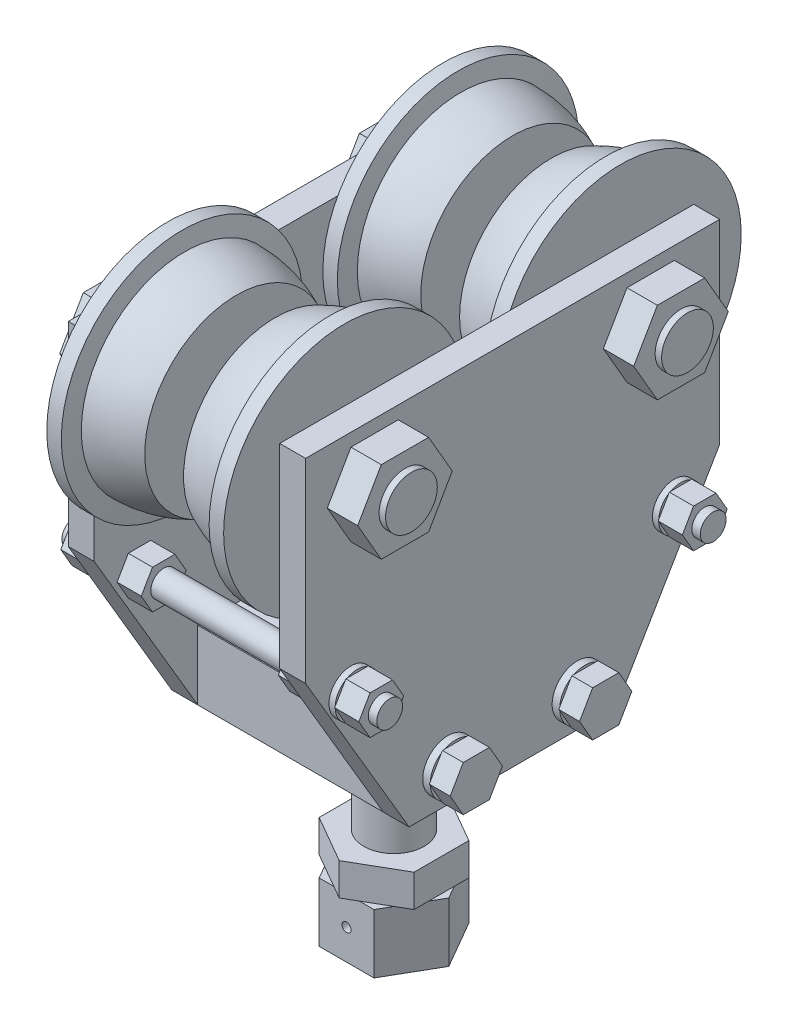
from build123d import *

# Parameters (mm, degrees)
YOKE_CROSS_SECTION_W           = 152.4
YOKE_CROSS_SECTION_H           = 50.8
YOKE_DEPTH                     = 68.2625
SIDEPLATE_DEPTH                = 19.05
WHEEL_PIN_NUT_DEPTH            = 22.352
WHEEL_PIN_PROJECTION_PROFILE_R = 19.05
WHEEL_PIN_PROJECTION_DEPTH     = 4.7625
LOCKNUTS_PROFILE_R             = 18.542
LOCKNUTS_DEPTH                 = 5.5626
SCREWS_DEPTH                   = 15.3416
PROFILE_R                      = 30.1625
KING_BOLT_HEAD_DEPTH           = 38.1
DIA_R                          = 22.225
KING_BOLT_DEPTH                = 83.052101
KING_BOLT_JAM_NUT_DEPTH        = 23.8125
KING_BOLT_NUT_DEPTH            = 43.6372
SKETCH5_R                      = 22.225
EXTENDED_KING_BOLT_DEPTH       = 9.525
CHAMFER1_SIZE                  = 2.38125
THREADED_START                 = -68.2625
SKETCH6_R                      = 9.525
THREADED_ROD_DEPTH             = 115.8875
THREADED_ROD_NUTS_INNER_DEPTH  = 17.8054
SKETCH8_R                      = 16.129
THREADED_ROD_LOCKWASHER_DEPTH  = 4.572
THREADED_ROD_NUT_OUTER_DEPTH   = 17.8054
MIRROR3_START                  = -68.2625
MIRROR3_COPY_1_SKETCH_R        = 9.525
MIRROR3_COPY_1_DEPTH           = 115.8875
MIRROR3_COPY_2_DEPTH           = 17.8054
MIRROR3_COPY_3_SKETCH_R        = 16.129
MIRROR3_COPY_3_DEPTH           = 4.572
MIRROR3_COPY_4_DEPTH           = 17.8054
SKETCH10_R                     = 3.3655
COTTER_PIN_HOLE_DEPTH          = 188.325


with BuildPart() as part:
    # YOKE CROSS SECTION → YOKE (new body)
    with BuildSketch(Plane(origin=(0, 0, 0), x_dir=(0, 0, -1), z_dir=(1, 0, 0))):
        with Locations((0, 25.4)):
            Rectangle(YOKE_CROSS_SECTION_W, YOKE_CROSS_SECTION_H)
    extrude(amount=YOKE_DEPTH)

    # SIDEPLATE PROFILE → SIDEPLATE (add)
    with BuildSketch(Plane(origin=(68.2625, 0, 0), x_dir=(0, 0, -1), z_dir=(1, 0, 0))):
        Polygon((-152.4, 273.05), (152.4, 273.05), (152.4, 129.54), (76.2, 0), (0, 0), (-76.2, 0), (-152.4, 129.54), align=None)
    extrude(amount=SIDEPLATE_DEPTH)

    # WHEEL PIN NUT PROFILE → WHEEL PIN NUT (add)
    with BuildSketch(Plane(origin=(87.3125, 0, 0), x_dir=(0, 0, -1), z_dir=(1, 0, 0))):
        Polygon((-66.771345011, 233.3625), (-84.185672506, 263.525), (-119.014327494, 263.525), (-136.428654989, 233.3625), (-119.014327494, 203.2), (-84.185672506, 203.2), align=None)
    wheel_pin_nut = extrude(amount=WHEEL_PIN_NUT_DEPTH)

    # WHEEL PIN PROJECTION PROFILE → WHEEL PIN PROJECTION (add)
    with BuildSketch(Plane(origin=(109.6645, 0, 0), x_dir=(0, 0, -1), z_dir=(1, 0, 0))):
        with Locations((-101.6, 233.3625)):
            Circle(WHEEL_PIN_PROJECTION_PROFILE_R)
    wheel_pin_projection = extrude(amount=WHEEL_PIN_PROJECTION_DEPTH)

    # LOCKNUTS PROFILE → LOCKNUTS (add)
    with BuildSketch(Plane(origin=(87.3125, 0, 0), x_dir=(0, 0, -1), z_dir=(1, 0, 0))):
        with Locations((-47.625, 25.4)):
            Circle(LOCKNUTS_PROFILE_R)
    locknuts = extrude(amount=LOCKNUTS_DEPTH)

    # SCREWS PROFILE → SCREWS (add)
    with BuildSketch(Plane(origin=(92.8751, 0, 0), x_dir=(0, 0, -1), z_dir=(1, 0, 0))):
        Polygon((-28.377585401, 25.4), (-38.0012927, 42.06875), (-57.2487073, 42.06875), (-66.872414599, 25.4), (-57.2487073, 8.73125), (-38.0012927, 8.73125), align=None)
    screws = extrude(amount=SCREWS_DEPTH)

    # PROFILE → KING BOLT HEAD (add)
    with BuildSketch(Plane(origin=(0, 50.8, 0), x_dir=(-1, 0, 0), z_dir=(0, 1, 0))):
        with Locations(Location((0, 0, 0), (0, 0, 90))):  # turned: the seam where the file's is
            Circle(PROFILE_R)
    extrude(amount=KING_BOLT_HEAD_DEPTH)

    # Mirror1: WHEEL PIN NUT, WHEEL PIN PROJECTION across plane
    add(wheel_pin_nut.mirror(Plane.XY))
    add(wheel_pin_projection.mirror(Plane.XY))

    # Mirror YOKE SCREWS: LOCKNUTS, SCREWS across plane
    add(locknuts.mirror(Plane.XY))
    add(screws.mirror(Plane.XY))

    # Mirror SIDE 1: part across plane


with BuildPart() as part_1:
    add(part.part)
    add(part.part.mirror(Plane(origin=(0, 0, 0), x_dir=(0, 0, 1), z_dir=(1, 0, 0))))

    # DIA. → KING BOLT (add)
    with BuildSketch(Plane.XZ):
        with Locations(Location((0, 0, 0), (0, 0, 90))):  # turned: the seam where the file's is
            Circle(DIA_R)
    extrude(amount=KING_BOLT_DEPTH)

    # KING BOLT JAN NUT PROFILE → KING BOLT JAM NUT (add)
    with BuildSketch(Plane.XZ.offset(83.052100888)):
        Polygon((0, -40.327916303), (34.925, -20.163958151), (34.925, 20.163958151), (0, 40.327916303), (-34.925, 20.163958151), (-34.925, -20.163958151), align=None)
    extrude(amount=KING_BOLT_JAM_NUT_DEPTH)

    # KING BOLT NUT PROFILE → KING BOLT NUT (add)
    with BuildSketch(Plane.XZ.offset(106.864600888)):
        Polygon((40.327916303, 0), (20.163958151, 34.925), (-20.163958151, 34.925), (-40.327916303, 0), (-20.163958151, -34.925), (20.163958151, -34.925), align=None)
    extrude(amount=KING_BOLT_NUT_DEPTH)

    # Sketch5 → EXTENDED KING BOLT (add)
    with BuildSketch(Plane.XZ.offset(150.501800888)):
        with Locations(Location((0, 0, 0), (0, 0, 90))):  # turned: the seam where the file's is
            Circle(SKETCH5_R)
    extrude(amount=EXTENDED_KING_BOLT_DEPTH)

    # Chamfer1
    chamfer1_edges = [part_1.edges().sort_by_distance(p)[0] for p in [
        (0, -160.026800888, -22.225),
    ]]
    chamfer(chamfer1_edges, length=CHAMFER1_SIZE)

    # Sketch6 → THREADED ROD (add)
    with BuildSketch(Plane(origin=(68.2625, 0, 0), x_dir=(0, 0, -1), z_dir=(1, 0, 0)).offset(THREADED_START)):
        with Locations((-119.0625, 107.95)):
            Circle(SKETCH6_R)
    threaded_rod = extrude(amount=THREADED_ROD_DEPTH)

    # Sketch7 → THREADED ROD NUTS INNER (add)
    with BuildSketch(Plane(origin=(68.2625, 0, 0), x_dir=(0, 0, -1), z_dir=(1, 0, 0))):
        Polygon((-102.564716058, 107.95), (-110.813608029, 122.2375), (-127.311391971, 122.2375), (-135.560283942, 107.95), (-127.311391971, 93.6625), (-110.813608029, 93.6625), align=None)
    threaded_rod_nuts_inner = extrude(amount=-THREADED_ROD_NUTS_INNER_DEPTH)

    # Sketch8 → THREADED ROD LOCKWASHER (add)
    with BuildSketch(Plane(origin=(87.3125, 0, 0), x_dir=(0, 0, -1), z_dir=(1, 0, 0))):
        with Locations((-119.0625, 107.95)):
            Circle(SKETCH8_R)
    threaded_rod_lockwasher = extrude(amount=THREADED_ROD_LOCKWASHER_DEPTH)

    # Sketch9 → THREADED ROD NUT OUTER (add)
    with BuildSketch(Plane(origin=(91.8845, 0, 0), x_dir=(0, 0, -1), z_dir=(1, 0, 0))):
        Polygon((-102.564716058, 107.95), (-110.813608029, 122.2375), (-127.311391971, 122.2375), (-135.560283942, 107.95), (-127.311391971, 93.6625), (-110.813608029, 93.6625), align=None)
    threaded_rod_nut_outer = extrude(amount=THREADED_ROD_NUT_OUTER_DEPTH)

    # Mirror2: THREADED ROD, THREADED ROD NUTS INNER, THREADED ROD LOCKWASHER, THREADED ROD NUT OUTER across plane
    add(threaded_rod.mirror(Plane.XY))
    add(threaded_rod_nuts_inner.mirror(Plane.XY))
    add(threaded_rod_lockwasher.mirror(Plane.XY))
    add(threaded_rod_nut_outer.mirror(Plane.XY))

    # Mirror3: THREADED ROD, THREADED ROD NUTS INNER, THREADED ROD LOCKWASHER, THREADED ROD NUT OUTER across plane
    add(threaded_rod.mirror(Plane(origin=(0, 0, 0), x_dir=(0, 0, 1), z_dir=(1, 0, 0))))
    add(threaded_rod_nuts_inner.mirror(Plane(origin=(0, 0, 0), x_dir=(0, 0, 1), z_dir=(1, 0, 0))))
    add(threaded_rod_lockwasher.mirror(Plane(origin=(0, 0, 0), x_dir=(0, 0, 1), z_dir=(1, 0, 0))))
    add(threaded_rod_nut_outer.mirror(Plane(origin=(0, 0, 0), x_dir=(0, 0, 1), z_dir=(1, 0, 0))))

    # Mirror3 copy 1 sketch → Mirror3 copy 1 (add)
    with BuildSketch(Plane.ZY.offset(68.2625).offset(MIRROR3_START)):
        with Locations((-119.0625, 107.95)):
            Circle(MIRROR3_COPY_1_SKETCH_R)
    extrude(amount=MIRROR3_COPY_1_DEPTH)

    # Mirror3 copy 2 sketch → Mirror3 copy 2 (add)
    with BuildSketch(Plane.ZY.offset(68.2625)):
        Polygon((-102.564716058, 107.95), (-110.813608029, 122.2375), (-127.311391971, 122.2375), (-135.560283942, 107.95), (-127.311391971, 93.6625), (-110.813608029, 93.6625), align=None)
    extrude(amount=-MIRROR3_COPY_2_DEPTH)

    # Mirror3 copy 3 sketch → Mirror3 copy 3 (add)
    with BuildSketch(Plane.ZY.offset(87.3125)):
        with Locations((-119.0625, 107.95)):
            Circle(MIRROR3_COPY_3_SKETCH_R)
    extrude(amount=MIRROR3_COPY_3_DEPTH)

    # Mirror3 copy 4 sketch → Mirror3 copy 4 (add)
    with BuildSketch(Plane.ZY.offset(91.8845)):
        Polygon((-102.564716058, 107.95), (-110.813608029, 122.2375), (-127.311391971, 122.2375), (-135.560283942, 107.95), (-127.311391971, 93.6625), (-110.813608029, 93.6625), align=None)
    extrude(amount=MIRROR3_COPY_4_DEPTH)

    # Sketch10 → COTTER PIN HOLE (cut, through all)
    with BuildSketch(Plane.XY.offset(34.925)):
        with Locations((0, -128.276800888)):
            Circle(SKETCH10_R)
    extrude(amount=-COTTER_PIN_HOLE_DEPTH, mode=Mode.SUBTRACT)

    # Sketch11 → WHEEL (revolve)
    with BuildSketch(Plane.XY.offset(101.6), mode=Mode.PRIVATE) as wheel_sk:
        with BuildLine():
            Line((68.2625, 233.3625), (14.2875, 233.3625))
            Line((14.2875, 233.3625), (14.2875, 300.984352568))
            ThreePointArc((14.2875, 300.984352568), (32.860629966, 307.391453335), (52.3875, 309.5625))
            Line((52.3875, 309.5625), (54.398982392, 322.2625))
            Line((54.398982392, 322.2625), (65.0875, 322.2625))
            Line((65.0875, 322.2625), (65.0875, 260.35))
            Line((65.0875, 260.35), (68.2625, 260.35))
            Line((68.2625, 260.35), (68.2625, 233.3625))
        make_face()
    wheel = revolve(wheel_sk.sketch.rotate(Axis((114.427, 233.3625, 101.6), (-1, 0, 0)), 90), axis=Axis((114.427, 233.3625, 101.6), (-1, 0, 0)))  # turned: the seam where the file's is

    # Mirror4: WHEEL across plane
    add(wheel.mirror(Plane.XY))

    # Mirror5: WHEEL across plane
    add(wheel.mirror(Plane(origin=(0, 0, 0), x_dir=(0, 0, 1), z_dir=(1, 0, 0))))

    # Mirror5 copy 1 sketch → Mirror5 copy 1 (revolve)
    with BuildSketch(Plane(origin=(0, 0, -101.6), x_dir=(-1, 0, 0), z_dir=(0, 0, -1))):
        with BuildLine():
            Line((68.2625, 233.3625), (14.2875, 233.3625))
            Line((14.2875, 233.3625), (14.2875, 300.984352568))
            ThreePointArc((14.2875, 300.984352568), (32.860629966, 307.391453335), (52.3875, 309.5625))
            Line((52.3875, 309.5625), (54.398982392, 322.2625))
            Line((54.398982392, 322.2625), (65.0875, 322.2625))
            Line((65.0875, 322.2625), (65.0875, 260.35))
            Line((65.0875, 260.35), (68.2625, 260.35))
            Line((68.2625, 260.35), (68.2625, 233.3625))
        make_face()
    revolve(axis=Axis((-114.427, 233.3625, -101.6), (1, 0, 0)))


solid = part_1.part
